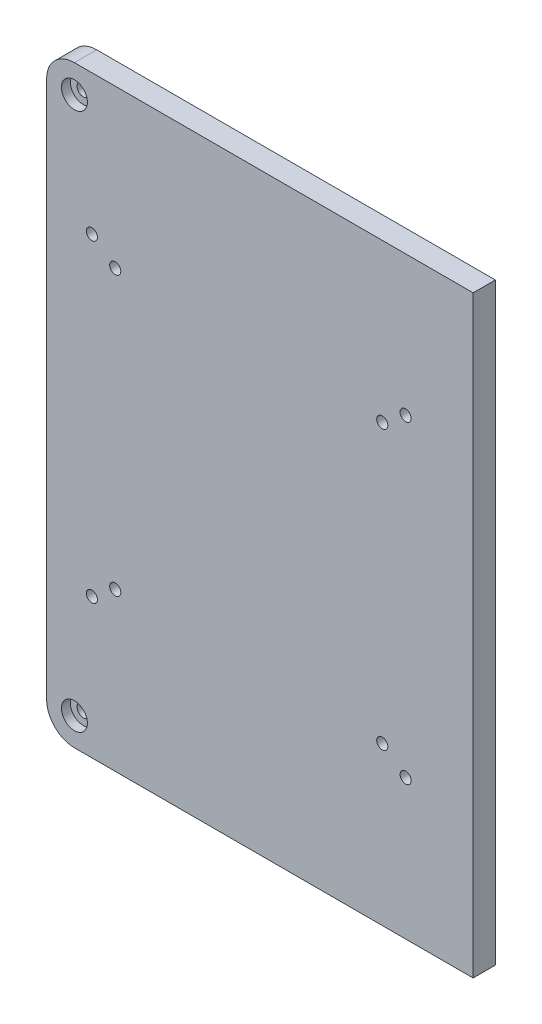
from build123d import *

# Parameters (mm, degrees)
BOSS_EXTRUDE1_DEPTH                              = 6
SKETCH4_R                                        = 1.5
CUT_EXTRUDE3_DEPTH                               = 7
SKETCH5_R                                        = 1.375
CUT_EXTRUDE4_DEPTH                               = 1
CUT_EXTRUDE4_DEPTH_BACK                          = 7
SKETCH7_R                                        = 1.5
CUT_EXTRUDE6_DEPTH                               = 7
SKETCH8_R                                        = 3
CUT_EXTRUDE7_DEPTH                               = 3.5
CBORE_FOR_M3_PAN_HEAD_MACHINE_SCREW1_D           = 3.4
CBORE_FOR_M3_PAN_HEAD_MACHINE_SCREW1_CBORE_D     = 7
CBORE_FOR_M3_PAN_HEAD_MACHINE_SCREW1_CBORE_DEPTH = 2.4
SKETCH11_W                                       = 115
SKETCH11_H                                       = 160
CUT_EXTRUDE8_DEPTH                               = 10


with BuildPart() as part:
    # Sketch1 → Boss-Extrude1 (new body)
    with BuildSketch(Plane.XY):
        with BuildLine():
            Line((-107.5, 80), (107.5, 80))
            ThreePointArc((107.5, 80), (112.803300859, 77.803300859), (115, 72.5))
            Line((115, 72.5), (115, -72.5))
            ThreePointArc((115, -72.5), (112.803300859, -77.803300859), (107.5, -80))
            Line((107.5, -80), (-107.5, -80))
            ThreePointArc((-107.5, -80), (-112.803300859, -77.803300859), (-115, -72.5))
            Line((-115, -72.5), (-115, 72.5))
            ThreePointArc((-115, 72.5), (-112.803300859, 77.803300859), (-107.5, 80))
        make_face()
    extrude(amount=BOSS_EXTRUDE1_DEPTH)

    # Sketch4 → Cut-Extrude3 (cut, through all)
    with BuildSketch(Plane.XY.offset(6)):
        with Locations((-96.5, 37.5)):
            Circle(SKETCH4_R)
        with Locations((-96.5, -37.5)):
            Circle(SKETCH4_R)
        with Locations((-24.5, 37.5)):
            Circle(SKETCH4_R)
        with Locations((-24.5, -37.5)):
            Circle(SKETCH4_R)
    extrude(amount=-CUT_EXTRUDE3_DEPTH, mode=Mode.SUBTRACT)

    # Sketch5 → Cut-Extrude4 (cut, two sides)
    with BuildSketch(Plane.XY.offset(6)) as cut_extrude4_sk:
        with Locations((95, -62.5)):
            Circle(SKETCH5_R)
        with Locations((95, 62.5)):
            Circle(SKETCH5_R)
        with Locations((41.7, -62.5)):
            Circle(SKETCH5_R)
        with Locations((41.7, 62.5)):
            Circle(SKETCH5_R)
    extrude(amount=CUT_EXTRUDE4_DEPTH, mode=Mode.SUBTRACT)
    extrude(cut_extrude4_sk.sketch, amount=-CUT_EXTRUDE4_DEPTH_BACK, mode=Mode.SUBTRACT)

    # Sketch7 → Cut-Extrude6 (cut, through all)
    with BuildSketch(Plane.XY.offset(6)):
        with Locations((-102.8, 42.3)):
            Circle(SKETCH7_R)
        with Locations((-102.8, -42.3)):
            Circle(SKETCH7_R)
        with Locations((-18.2, -42.3)):
            Circle(SKETCH7_R)
        with Locations((-18.2, 42.3)):
            Circle(SKETCH7_R)
    extrude(amount=-CUT_EXTRUDE6_DEPTH, mode=Mode.SUBTRACT)

    # Sketch8 → Cut-Extrude7 (cut)
    with BuildSketch(Plane(origin=(0, 0, 0), x_dir=(-1, 0, 0), z_dir=(0, 0, -1))):
        with Locations((18.2, 42.3)):
            Circle(SKETCH8_R)
        with Locations((18.2, -42.3)):
            Circle(SKETCH8_R)
        with Locations((102.8, -42.3)):
            Circle(SKETCH8_R)
        with Locations((102.8, 42.3)):
            Circle(SKETCH8_R)
    extrude(amount=-CUT_EXTRUDE7_DEPTH, mode=Mode.SUBTRACT)

    # CBORE for M3 Pan Head Machine Screw1 (through all)
    with Locations(Plane.XY.offset(6)):
        with Locations((-107.5, 72.5), (-107.5, -72.5), (107.5, -72.5), (107.5, 72.5)):
            CounterBoreHole(CBORE_FOR_M3_PAN_HEAD_MACHINE_SCREW1_D / 2, CBORE_FOR_M3_PAN_HEAD_MACHINE_SCREW1_CBORE_D / 2, CBORE_FOR_M3_PAN_HEAD_MACHINE_SCREW1_CBORE_DEPTH)

    # Sketch11 → Cut-Extrude8 (cut)
    with BuildSketch(Plane(origin=(0, 0, 0), x_dir=(-1, 0, 0), z_dir=(0, 0, -1))):
        with Locations((-57.5, 0)):
            Rectangle(SKETCH11_W, SKETCH11_H)
    extrude(amount=-CUT_EXTRUDE8_DEPTH, mode=Mode.SUBTRACT)


solid = part.part
